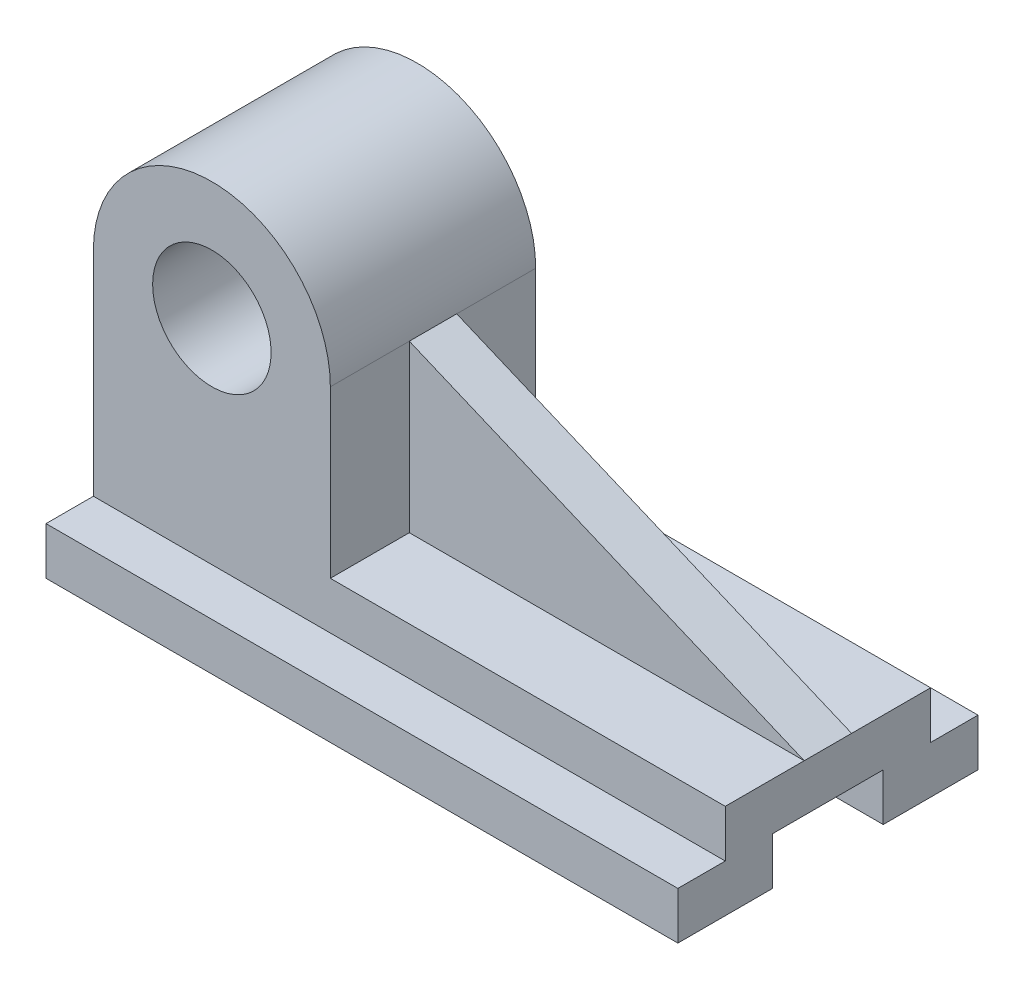
from build123d import *

# Parameters (mm, degrees)
SKETCH3_W           = 160
SKETCH3_H           = 12
BOSS_EXTRUDE2_DEPTH = 26
SKETCH4_W           = 160
SKETCH4_H           = 12
BOSS_EXTRUDE3_DEPTH = 12
SKETCH5_W           = 160
SKETCH5_H           = 12
BOSS_EXTRUDE4_DEPTH = 12
SKETCH8_R           = 15
BOSS_EXTRUDE5_DEPTH = 52
RIB1_REACH          = 120.017
SKETCH14_WALL_W     = 346.495870774
SKETCH14_WALL_H     = 12


with BuildPart() as part:
    # Sketch3 → Boss-Extrude2 (new, symmetric)
    with BuildSketch(Plane.XY):
        Rectangle(SKETCH3_W, SKETCH3_H)
    extrude(amount=BOSS_EXTRUDE2_DEPTH, both=True)

    # Sketch4 → Boss-Extrude3 (add, symmetric)
    with BuildSketch(Plane.XY.offset(26)):
        with Locations((0, -12)):
            Rectangle(SKETCH4_W, SKETCH4_H)
    extrude(amount=BOSS_EXTRUDE3_DEPTH, both=True)

    # Sketch5 → Boss-Extrude4 (add, symmetric)
    with BuildSketch(Plane(origin=(0, 0, -26), x_dir=(-1, 0, 0), z_dir=(0, 0, -1))):
        with Locations((0, -12)):
            Rectangle(SKETCH5_W, SKETCH5_H)
    extrude(amount=BOSS_EXTRUDE4_DEPTH, both=True)

    # Sketch8 → Boss-Extrude5 (add)
    with BuildSketch(Plane(origin=(0, 0, -26), x_dir=(-1, 0, 0), z_dir=(0, 0, -1))):
        with BuildLine():
            Line((20, 6), (80, 6))
            Line((80, 6), (80, 48))
            ThreePointArc((80, 48), (50, 78), (20, 48))
            Line((20, 48), (20, 6))
        make_face()
        with Locations((50, 48)):
            Circle(SKETCH8_R, mode=Mode.SUBTRACT)
    extrude(amount=-BOSS_EXTRUDE5_DEPTH)

    # Sketch14 wall → Rib1 (add, up to next)
    with BuildSketch(Plane(origin=(30, 27, 0), x_dir=(0.921982105607, -0.387232484355, 0), z_dir=(0.387232484355, 0.921982105607, 0)), mode=Mode.PRIVATE) as rib1_sk1:
        Rectangle(SKETCH14_WALL_W, SKETCH14_WALL_H)
    rib1_tool1 = extrude(rib1_sk1.sketch, amount=-RIB1_REACH, mode=Mode.PRIVATE) - part.part
    add(rib1_tool1.solids().sort_by_distance((30, 27, 0))[0])


solid = part.part
